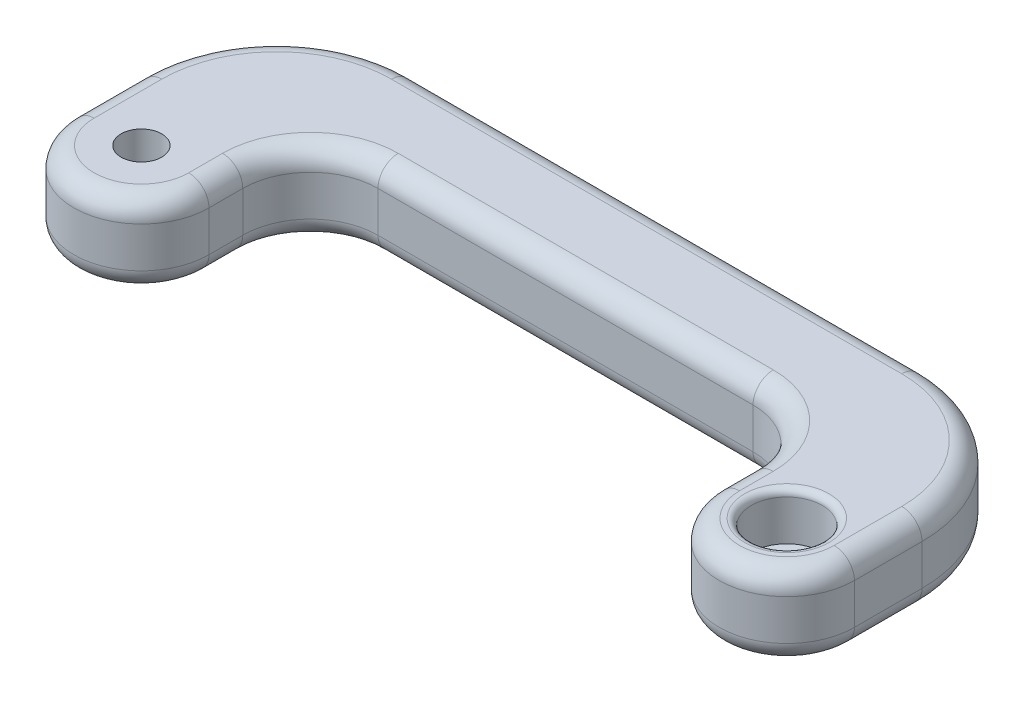
from build123d import *

# Parameters (mm, degrees)
SKETCH7_R           = 5
BOSS_EXTRUDE5_DEPTH = 12
FILLET2_R           = 20
FILLET3_R           = 10
FILLET5_R           = 3
SKETCH11_R          = 5.25
CUT_EXTRUDE1_DEPTH  = 36
FILLET6_R           = 1
SKETCH12_R          = 6.25
SKETCH12_R_2        = 3
BOSS_EXTRUDE6_DEPTH = 5
SKETCH13_R          = 6.25
SKETCH13_R_2        = 3
BOSS_EXTRUDE7_DEPTH = 5


with BuildPart() as part:
    # Sketch7 → Boss-Extrude5 (new body)
    with BuildSketch(Plane(origin=(0, 0, 0), x_dir=(1, 0, 0), z_dir=(0, 1, 0))):
        with BuildLine():
            Line((-105.5, 30), (-105.5, 0))
            ThreePointArc((-105.5, 0), (-95.5, -10), (-85.5, 0))
            Line((-85.5, 0), (-85.5, 15))
            Line((-85.5, 15), (-10, 15))
            Line((-10, 15), (-10, 0))
            ThreePointArc((-10, 0), (0, -10), (10, 0))
            Line((10, 0), (10, 30))
            Line((10, 30), (-10, 30))
            Line((-10, 30), (-85.5, 30))
            Line((-85.5, 30), (-105.5, 30))
        make_face()
        with Locations((-95.5, 0)):
            Circle(SKETCH7_R, mode=Mode.SUBTRACT)
    extrude(amount=BOSS_EXTRUDE5_DEPTH)

    # Fillet2
    fillet2_edges = [part.edges().sort_by_distance(p)[0] for p in [
        (-105.5, 6, -30),
        (10, 6, -30),
    ]]
    fillet(fillet2_edges, radius=FILLET2_R)

    # Fillet3
    fillet3_edges = [part.edges().sort_by_distance(p)[0] for p in [
        (-10, 6, -15),
        (-85.5, 6, -15),
    ]]
    fillet(fillet3_edges, radius=FILLET3_R)

    # Fillet5
    fillet5_edges = [part.edges().sort_by_distance(p)[0] for p in [
        (10, 0, -5),
        (-105.5, 12, -5),
        (0, 0, 10),
        (-10, 0, -2.5),
        (-85.5, 0, -2.5),
        (-95.5, 0, 10),
        (-105.5, 0, -5),
        (-95.5, 12, 10),
        (-85.5, 12, -2.5),
        (-47.75, 0, -30),
        (-47.75, 12, -30),
        (-10, 12, -2.5),
        (-99.642135624, 0, -24.142135624),
        (4.142135624, 0, -24.142135624),
        (-99.642135624, 12, -24.142135624),
        (4.142135624, 12, -24.142135624),
        (0, 12, 10),
        (10, 12, -5),
        (-47.75, 0, -15),
        (-47.75, 12, -15),
        (-12.928932188, 0, -12.071067812),
        (-12.928932188, 12, -12.071067812),
        (-82.571067812, 0, -12.071067812),
        (-82.571067812, 12, -12.071067812),
    ]]
    fillet(fillet5_edges, radius=FILLET5_R)

    # Sketch11 → Cut-Extrude1 (cut)
    with BuildSketch(Plane.XZ):
        with Locations((-95.5, 0)):
            Circle(SKETCH11_R)
        Circle(SKETCH11_R)
    extrude(amount=-CUT_EXTRUDE1_DEPTH, mode=Mode.SUBTRACT)

    # Fillet6
    fillet6_edges = [part.edges().sort_by_distance(p)[0] for p in [
        (-100.75, 12, 0),
        (-100.75, 0, 0),
        (-5.25, 12, 0),
        (-5.25, 0, 0),
    ]]
    fillet(fillet6_edges, radius=FILLET6_R)

    # Sketch12 → Boss-Extrude6 (add)
    with BuildSketch(Plane(origin=(0, 12, 0), x_dir=(1, 0, 0), z_dir=(0, 1, 0))):
        with Locations((-95.5, 0)):
            Circle(SKETCH12_R)
        with Locations((-95.5, 0)):
            Circle(SKETCH12_R_2, mode=Mode.SUBTRACT)
    extrude(amount=-BOSS_EXTRUDE6_DEPTH)

    # Sketch13 → Boss-Extrude7 (add)
    with BuildSketch(Plane.XZ):
        Circle(SKETCH13_R)
        Circle(SKETCH13_R_2, mode=Mode.SUBTRACT)
    extrude(amount=-BOSS_EXTRUDE7_DEPTH)


solid = part.part
